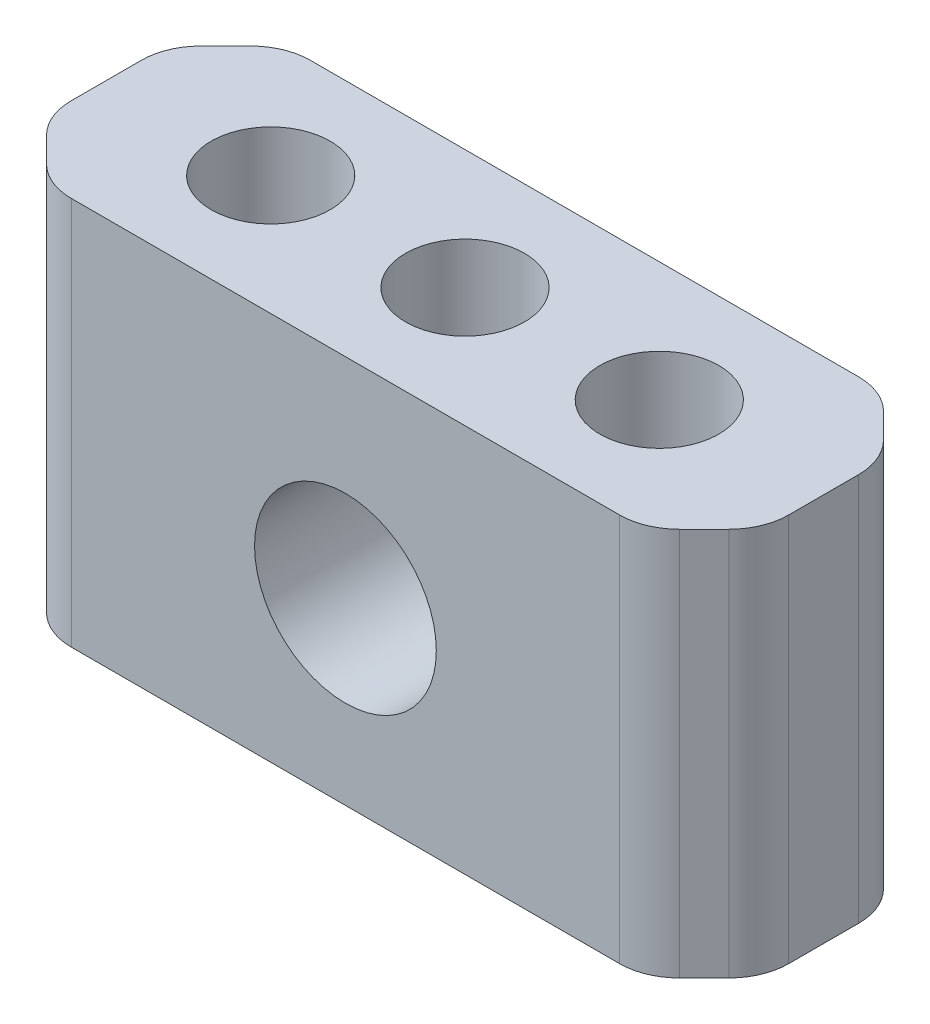
from build123d import *

# Parameters (mm, degrees)
BOSS_EXTRUDE1_DEPTH      = 4
BOSS_EXTRUDE1_DEPTH_BACK = 4
SKETCH1_W                = 24
SKETCH1_H                = 13
CUT_EXTRUDE1_DEPTH       = 7
CUT_EXTRUDE1_DEPTH_BACK  = 7
SKETCH3_R                = 3.04
SKETCH4_R                = 1.99
CUT_EXTRUDE2_DEPTH       = 10
SKETCH5_R                = 1.99
CUT_EXTRUDE4_DEPTH       = 3.9
CHAMFER1_SIZE            = 2
FILLET1_R                = 2


with BuildPart() as part:
    # Sketch1 → Boss-Extrude1 (new, two sides: drawn at the far end of the back side and taken through both)
    with BuildSketch(Plane.XY.offset(-BOSS_EXTRUDE1_DEPTH_BACK)):
        Rectangle(SKETCH1_W, SKETCH1_H)
    extrude(amount=BOSS_EXTRUDE1_DEPTH + BOSS_EXTRUDE1_DEPTH_BACK)

    # Sketch3 → Cut-Extrude1 (cut, two sides: drawn at the far end of the back side and taken through both)
    with BuildSketch(Plane.XY.offset(-CUT_EXTRUDE1_DEPTH_BACK)):
        with Locations((0, -0.5)):
            Circle(SKETCH3_R)
    extrude(amount=CUT_EXTRUDE1_DEPTH + CUT_EXTRUDE1_DEPTH_BACK, mode=Mode.SUBTRACT)

    # Sketch4 → Cut-Extrude2 (cut)
    with BuildSketch(Plane(origin=(0, 6.5, 0), x_dir=(1, 0, 0), z_dir=(0, 1, 0))):
        with Locations((-6.5, 0)):
            Circle(SKETCH4_R)
        with Locations((6.5, 0)):
            Circle(SKETCH4_R)
    extrude(amount=-CUT_EXTRUDE2_DEPTH, mode=Mode.SUBTRACT)

    # Sketch5 → Cut-Extrude4 (cut)
    with BuildSketch(Plane(origin=(0, 6.5, 0), x_dir=(1, 0, 0), z_dir=(0, 1, 0))):
        Circle(SKETCH5_R)
    extrude(amount=-CUT_EXTRUDE4_DEPTH, mode=Mode.SUBTRACT)

    # Chamfer1
    chamfer1_edges = [part.edges().sort_by_distance(p)[0] for p in [
        (12, 0, 4),
        (12, 0, -4),
        (-12, 0, 4),
        (-12, 0, -4),
    ]]
    chamfer(chamfer1_edges, length=CHAMFER1_SIZE)

    # Fillet1
    fillet1_edges = [part.edges().sort_by_distance(p)[0] for p in [
        (10, 0, 4),
        (-10, 0, 4),
        (-12, 0, 2),
        (-12, 0, -2),
        (-10, 0, -4),
        (12, 0, 2),
        (12, 0, -2),
        (10, 0, -4),
    ]]
    fillet(fillet1_edges, radius=FILLET1_R)


solid = part.part
